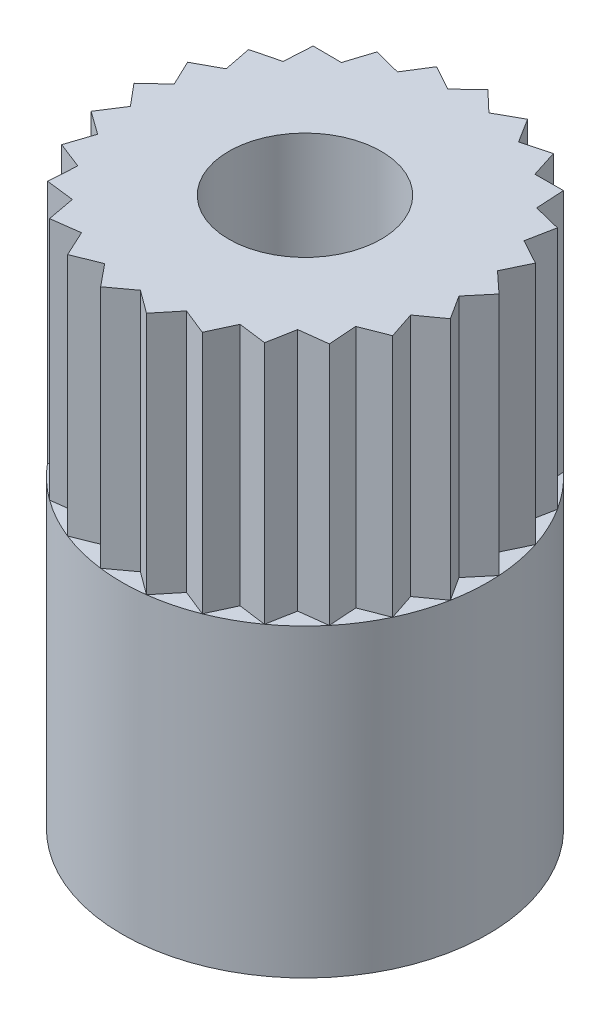
from build123d import *

# Parameters (mm, degrees)
SKETCH_1_R           = 3
EXTRUDE_1_DEPTH      = 5
EXTRUDE_1_DEPTH_BACK = 4
SKETCH_2_OUTSIDE_W   = 10.474
SKETCH_2_OUTSIDE_H   = 10.474
CUT_EXTRUDE_1_DEPTH  = 4
SKETCH_3_R           = 1.25
CUT_EXTRUDE_2_DEPTH  = 7


with BuildPart() as part:
    # Эскиз1 → Бобышка-Вытянуть1 (new body, two sides)
    with BuildSketch(Plane(origin=(0, 0, 0), x_dir=(1, 0, 0), z_dir=(0, 1, 0))) as extrude_1_sk:
        Circle(SKETCH_1_R)
    extrude(amount=EXTRUDE_1_DEPTH)
    extrude(extrude_1_sk.sketch, amount=-EXTRUDE_1_DEPTH_BACK)

    # Эскиз2 outside → Вырез-Вытянуть1 (cut)
    with BuildSketch(Plane(origin=(0, 5, 0), x_dir=(1, 0, 0), z_dir=(0, 1, 0))):
        Rectangle(SKETCH_2_OUTSIDE_W, SKETCH_2_OUTSIDE_H)
        Polygon((0, 3), (0.338399731, 2.678709694), (0.746069661, 2.905749483), (0.993936292, 2.510396512), (1.445261022, 2.62892004), (1.587020181, 2.184345885), (2.053641318, 2.186905882), (2.080385755, 1.721044772), (2.532983777, 1.607480385), (2.443033042, 1.149604087), (2.853169549, 0.927050983), (2.652175577, 0.505929549), (2.994080185, 0.188371559), (2.694672167, -0.169534403), (2.946861752, -0.562143944), (2.567852594, -0.834345885), (2.714481157, -1.277337875), (2.279685399, -1.446732346), (2.311539728, -1.912271969), (1.848277186, -1.968215294), (1.763355757, -2.427050983), (1.30073492, -2.366028036), (1.104373658, -2.789329458), (0.671462695, -2.615174535), (0.375999701, -2.976344104), (0, -2.7), (-0.375999701, -2.976344104), (-0.671462695, -2.615174535), (-1.104373658, -2.789329458), (-1.30073492, -2.366028036), (-1.763355757, -2.427050983), (-1.848277186, -1.968215294), (-2.311539728, -1.912271969), (-2.279685399, -1.446732346), (-2.714481157, -1.277337875), (-2.567852594, -0.834345885), (-2.946861752, -0.562143944), (-2.694672167, -0.169534403), (-2.994080185, 0.188371559), (-2.652175577, 0.505929549), (-2.853169549, 0.927050983), (-2.443033042, 1.149604087), (-2.532983777, 1.607480385), (-2.080385755, 1.721044772), (-2.053641318, 2.186905882), (-1.587020181, 2.184345885), (-1.445261022, 2.62892004), (-0.993936292, 2.510396512), (-0.746069661, 2.905749483), (-0.338399731, 2.678709694), align=None, mode=Mode.SUBTRACT)
    extrude(amount=-CUT_EXTRUDE_1_DEPTH, mode=Mode.SUBTRACT)

    # Эскиз3 → Вырез-Вытянуть2 (cut)
    with BuildSketch(Plane(origin=(0, 5, 0), x_dir=(1, 0, 0), z_dir=(0, 1, 0))):
        Circle(SKETCH_3_R)
    extrude(amount=-CUT_EXTRUDE_2_DEPTH, mode=Mode.SUBTRACT)


solid = part.part
